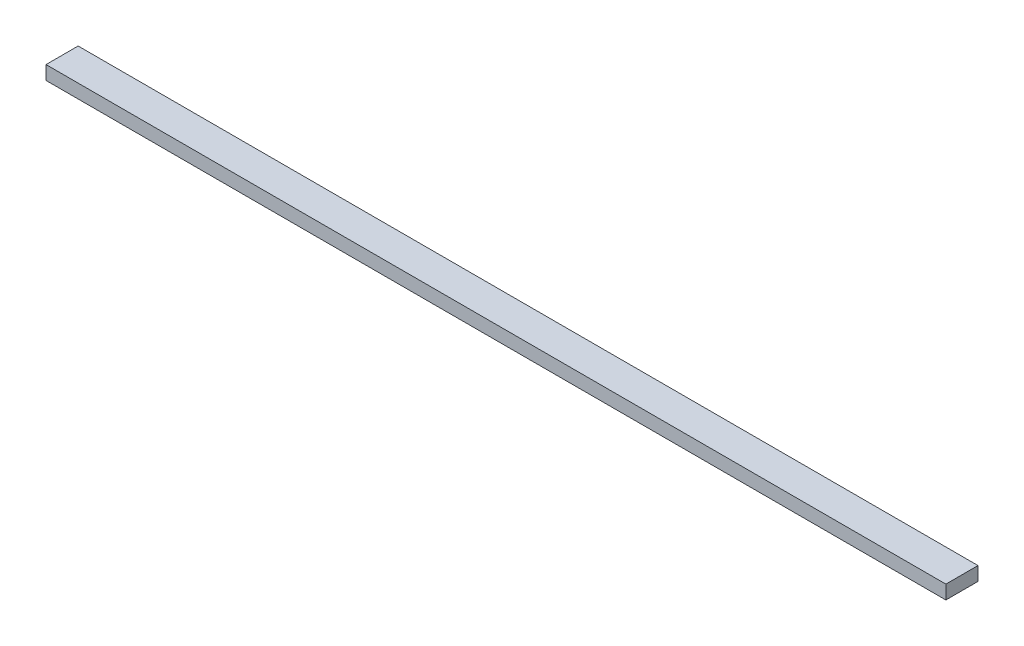
from build123d import *

# Parameters (mm, degrees)
SKETCH1_W           = 2489.2
SKETCH1_H           = 88.9
BOSS_EXTRUDE1_DEPTH = 38.1


with BuildPart() as part:
    # Sketch1 → Boss-Extrude1 (new body)
    with BuildSketch(Plane(origin=(0, 0, 0), x_dir=(1, 0, 0), z_dir=(0, 1, 0))):
        with Locations((1244.6, -44.45)):
            Rectangle(SKETCH1_W, SKETCH1_H)
    extrude(amount=BOSS_EXTRUDE1_DEPTH)


solid = part.part
